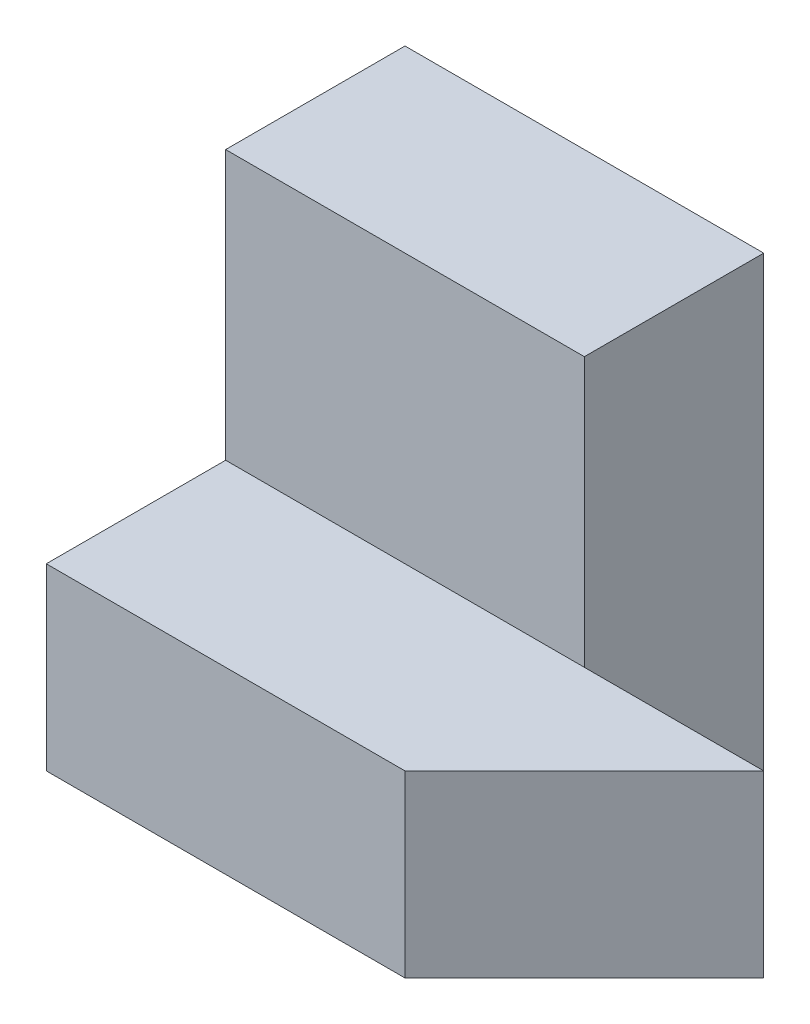
from build123d import *

# Parameters (mm, degrees)
SKETCH1_W           = 4
SKETCH1_H           = 5
BOSS_EXTRUDE1_DEPTH = 2
SKETCH2_W           = 4
SKETCH2_H           = 2
BOSS_EXTRUDE2_DEPTH = 2
BOSS_EXTRUDE3_DEPTH = 2


with BuildPart() as part:
    # Sketch1 → Boss-Extrude1 (new body)
    with BuildSketch(Plane.XY):
        Rectangle(SKETCH1_W, SKETCH1_H)
    extrude(amount=BOSS_EXTRUDE1_DEPTH)

    # Sketch2 → Boss-Extrude2 (add)
    with BuildSketch(Plane.XY.offset(2)):
        with Locations((0, -1.5)):
            Rectangle(SKETCH2_W, SKETCH2_H)
    extrude(amount=BOSS_EXTRUDE2_DEPTH)

    # Sketch3 → Boss-Extrude3 (add)
    with BuildSketch(Plane(origin=(0, -0.5, 0), x_dir=(1, 0, 0), z_dir=(0, 1, 0))):
        Polygon((2, -4), (4, -2), (2, -2), align=None)
    extrude(amount=-BOSS_EXTRUDE3_DEPTH)


solid = part.part
